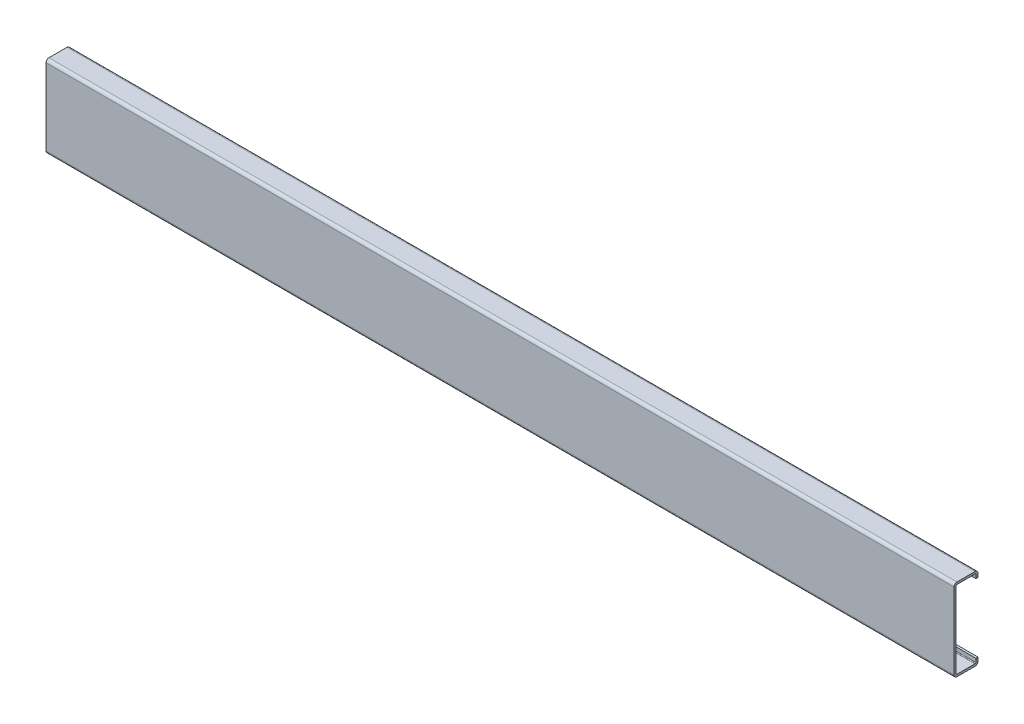
from build123d import *

# Parameters (mm, degrees)
EXTRUDE_1_DEPTH = 500


with BuildPart() as part:
    # Эскиз1 → Вытянуть-Тонкостенный1 (new body)
    with BuildSketch(Plane(origin=(0, 0, 0), x_dir=(0, 0, -1), z_dir=(1, 0, 0))):
        with BuildLine():
            Line((11.4, -19), (11.4, -21))
            ThreePointArc((11.4, -21), (11.282842712, -21.282842712), (11, -21.4))
            Line((11, -21.4), (1, -21.4))
            ThreePointArc((1, -21.4), (0.717157288, -21.282842712), (0.6, -21))
            Line((0.6, -21), (0.6, 21))
            ThreePointArc((0.6, 21), (0.717157288, 21.282842712), (1, 21.4))
            Line((1, 21.4), (11, 21.4))
            ThreePointArc((11, 21.4), (11.282842712, 21.282842712), (11.4, 21))
            Line((11.4, 21), (11.4, 19))
            Line((11.4, 19), (12.6, 19))
            Line((12.6, 19), (12.6, 21))
            ThreePointArc((12.6, 21), (12.13137085, 22.13137085), (11, 22.6))
            Line((11, 22.6), (1, 22.6))
            ThreePointArc((1, 22.6), (-0.13137085, 22.13137085), (-0.6, 21))
            Line((-0.6, 21), (-0.6, -21))
            ThreePointArc((-0.6, -21), (-0.13137085, -22.13137085), (1, -22.6))
            Line((1, -22.6), (11, -22.6))
            ThreePointArc((11, -22.6), (12.13137085, -22.13137085), (12.6, -21))
            Line((12.6, -21), (12.6, -19))
            Line((12.6, -19), (11.4, -19))
        make_face()
    extrude(amount=EXTRUDE_1_DEPTH)


solid = part.part
